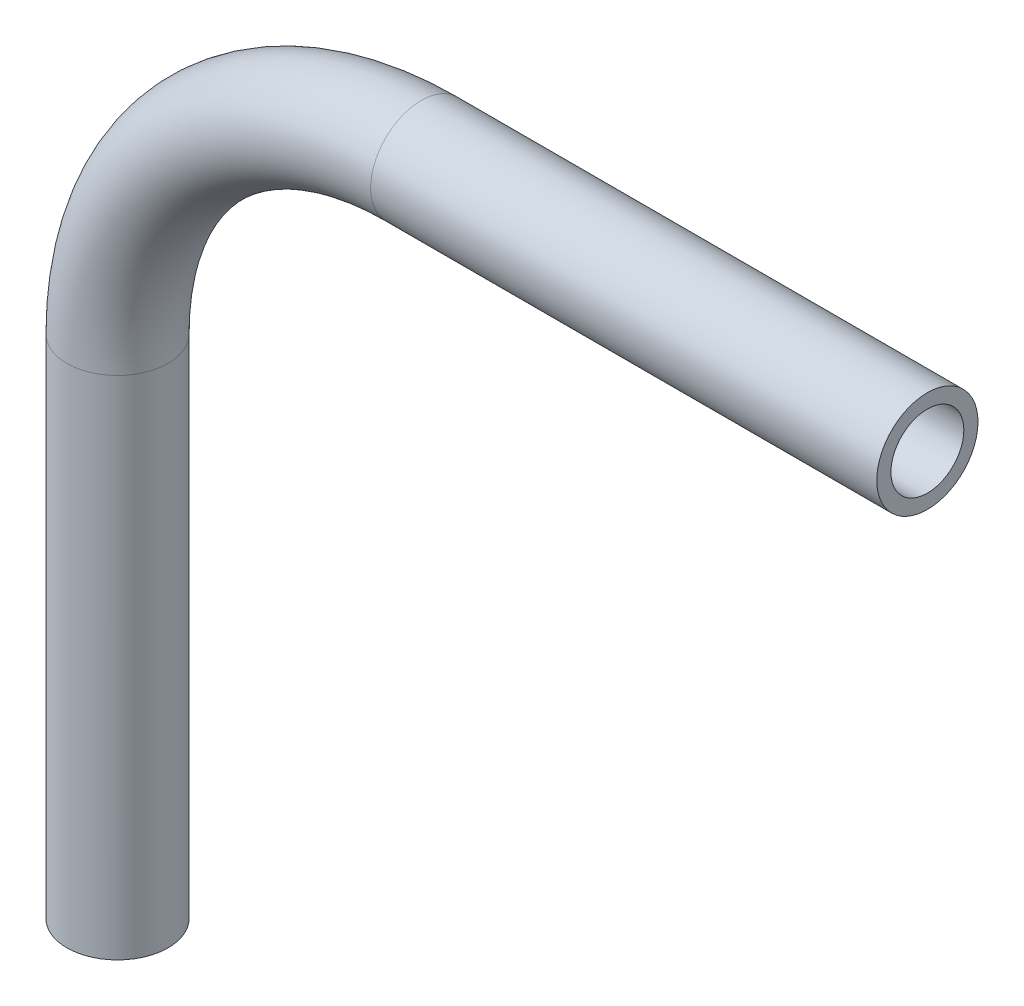
from build123d import *

# Parameters (mm, degrees)
SKETCH2_R   = 3.175
SKETCH2_R_2 = 2.286


with BuildPart() as part:
    # Sweep1: sweep along a path in Sketch1
    with BuildLine(Plane.XY) as sweep1_path:
        Line((0, -33.272317881), (0, -1.522317881))
        ThreePointArc((0, -1.522317881), (5.579615818, 11.948066301), (19.05, 17.527682119))
        Line((19.05, 17.527682119), (50.8, 17.527682119))
    # Sketch2 → Sweep1 (sweep)
    with BuildSketch(Plane(origin=(50.8, 17.527682119, 0), x_dir=(0, 0, -1), z_dir=(1, 0, 0))):
        Circle(SKETCH2_R)
        Circle(SKETCH2_R_2, mode=Mode.SUBTRACT)
    sweep(path=sweep1_path.line)


solid = part.part
